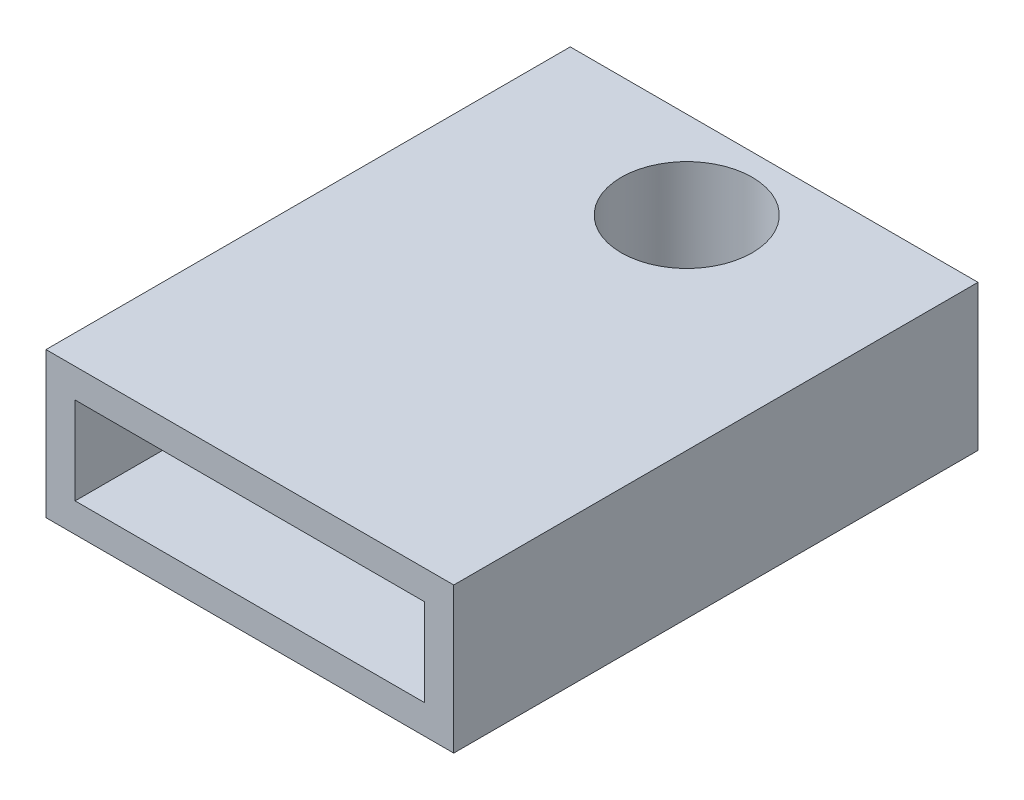
from build123d import *

# Parameters (mm, degrees)
SKETCH1_W                 = 14
SKETCH1_H                 = 5
BOSS_EXTRUDE1_DEPTH       = 18
SKETCH2_W                 = 12
SKETCH2_H                 = 3
CUT_EXTRUDE1_DEPTH        = 8
F_8_CLEARANCE_HOLE1_D     = 4.4958
F_8_CLEARANCE_HOLE1_DEPTH = 17
F_8_CLEARANCE_HOLE1_TIP   = 1.350674586


with BuildPart() as part:
    # Sketch1 → Boss-Extrude1 (new body)
    with BuildSketch(Plane.XY):
        with Locations((2.953810723, -0.588235294)):
            Rectangle(SKETCH1_W, SKETCH1_H)
    extrude(amount=-BOSS_EXTRUDE1_DEPTH)

    # Sketch2 → Cut-Extrude1 (cut)
    with BuildSketch(Plane.XY):
        with Locations((2.953810723, -0.588235294)):
            Rectangle(SKETCH2_W, SKETCH2_H)
    extrude(amount=-CUT_EXTRUDE1_DEPTH, mode=Mode.SUBTRACT)

    # #8 Clearance Hole1
    with Locations(Plane(origin=(2.953810723, -3.088235294, -15), x_dir=(0, 0, -1), z_dir=(0, -1, 0))):
        with Locations((0, 0)):
            Hole(F_8_CLEARANCE_HOLE1_D / 2, depth=F_8_CLEARANCE_HOLE1_DEPTH)
            with Locations((0, 0, -(F_8_CLEARANCE_HOLE1_DEPTH + F_8_CLEARANCE_HOLE1_TIP / 2))):  # 118° drill point
                Cone(0, F_8_CLEARANCE_HOLE1_D / 2, F_8_CLEARANCE_HOLE1_TIP, mode=Mode.SUBTRACT)


solid = part.part
